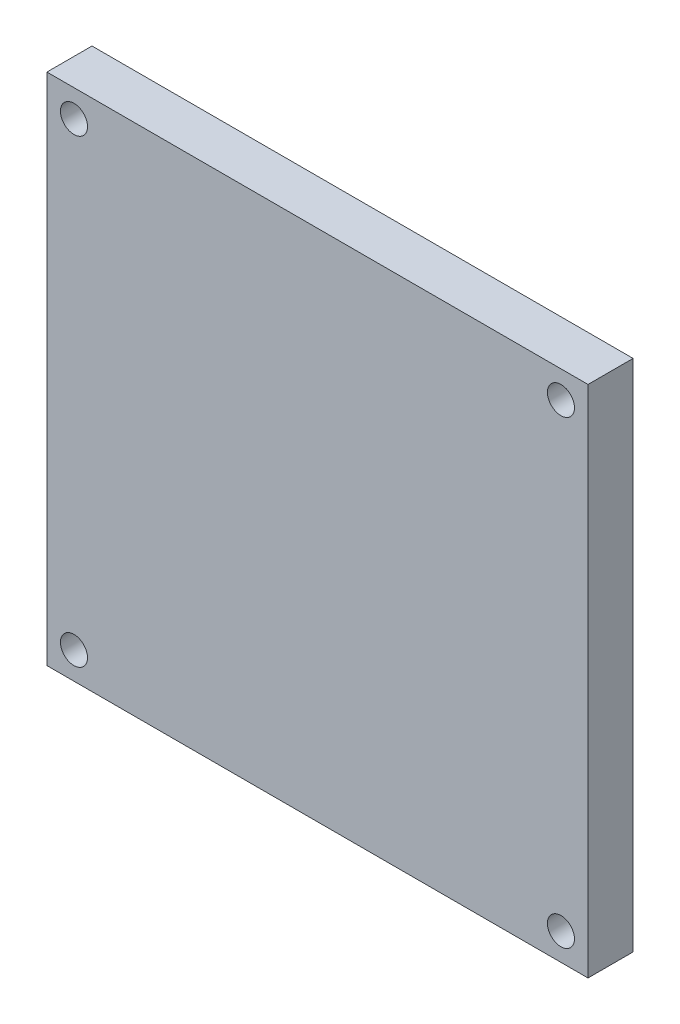
from build123d import *

# Parameters (mm, degrees)
SKETCH1_W           = 60
SKETCH1_H           = 57
BOSS_EXTRUDE1_DEPTH = 5
SKETCH2_W           = 2.280405405
SKETCH2_H           = 8
BOSS_EXTRUDE2_DEPTH = 1
SKETCH4_R           = 2.51
CUT_EXTRUDE1_DEPTH  = 1.5
SKETCH5_R           = 1.5
CUT_EXTRUDE2_DEPTH  = 5


with BuildPart() as part:
    # Sketch1 → Boss-Extrude1 (new body)
    with BuildSketch(Plane.XY):
        Rectangle(SKETCH1_W, SKETCH1_H)
    extrude(amount=BOSS_EXTRUDE1_DEPTH)

    # Sketch2 → Boss-Extrude2 (add)
    with BuildSketch(Plane(origin=(0, 0, 0), x_dir=(-1, 0, 0), z_dir=(0, 0, -1))):
        with BuildLine():
            Line((-24.20150669, -3.89957832), (-24.20150669, -1.614105347))
            Line((-24.20150669, -1.614105347), (-19.926168852, -1.614105347))
            add(Edge.make_bspline(
                [(-19.926168852, -1.614105347), (-19.887691328, -1.610282003), (-19.810774564, -1.602639119), (-19.717957698, -1.527413627), (-19.650822338, -1.426805485), (-19.644108729, -1.346040469), (-19.640695879, -1.304983726)],
                knots=[0, 0, 0, 0, 0.000113629, 0.000227144, 0.000344783, 0.000466416, 0.000466416, 0.000466416, 0.000466416], degree=3))
            add(Edge.make_bspline(
                [(-19.640695879, -1.304983726), (-19.644108729, -1.263926982), (-19.650822338, -1.183161967), (-19.717957698, -1.082553825), (-19.810774564, -1.007328333), (-19.887691328, -0.999685448), (-19.926168852, -0.995862104)],
                knots=[0, 0, 0, 0, 0.000121633, 0.000239272, 0.000352787, 0.000466416, 0.000466416, 0.000466416, 0.000466416], degree=3))
            Line((-19.926168852, -0.995862104), (-21.635628311, -0.995862104))
            add(Edge.make_bspline(
                [(-21.635628311, -0.995862104), (-21.722473931, -0.993687445), (-21.894088423, -0.989390129), (-22.145639266, -0.952415099), (-22.388446121, -0.895984066), (-22.620266099, -0.811525035), (-22.844531839, -0.707369457), (-23.057678623, -0.577615131), (-23.262284708, -0.426708764), (-23.452649356, -0.251991866), (-23.62635629, -0.060773048), (-23.782239865, 0.13987696), (-23.910026427, 0.352980665), (-24.018645568, 0.572977257), (-24.098985678, 0.804899998), (-24.158606031, 1.045612576), (-24.194868577, 1.296395056), (-24.199276132, 1.466857473), (-24.20150669, 1.553124382)],
                knots=[0, 0, 0, 0, 0.000260404, 0.00051458, 0.000761225, 0.001007001, 0.001253345, 0.001501902, 0.001754271, 0.002014932, 0.002275593, 0.002528645, 0.002775757, 0.003019779, 0.003263398, 0.003510441, 0.003762945, 0.004021662, 0.004021662, 0.004021662, 0.004021662], degree=3))
            add(Edge.make_bspline(
                [(-24.20150669, 1.553124382), (-24.199310434, 1.639395898), (-24.194984855, 1.809309767), (-24.158406918, 2.059479724), (-24.099003992, 2.299663062), (-24.018635935, 2.531577197), (-23.910046905, 2.751596069), (-23.782165923, 2.964617592), (-23.626896484, 3.165255727), (-23.452125797, 3.354980687), (-23.261800857, 3.529458704), (-23.058230483, 3.682361328), (-22.844462419, 3.811833778), (-22.620284578, 3.916109966), (-22.388441162, 4.000536837), (-22.145640635, 4.056976553), (-21.894088066, 4.093949215), (-21.722473811, 4.098246856), (-21.635628311, 4.10042168)],
                knots=[0, 0, 0, 0, 0.000258716, 0.000509548, 0.000756592, 0.00100021, 0.001244232, 0.001491345, 0.001744396, 0.002003812, 0.002264473, 0.002517852, 0.002766409, 0.003012753, 0.003258529, 0.003505174, 0.00375935, 0.004019754, 0.004019754, 0.004019754, 0.004019754], degree=3))
            Line((-21.635628311, 4.10042168), (-17.360290473, 4.10042168))
            Line((-17.360290473, 4.10042168), (-17.360290473, 1.814948707))
            Line((-17.360290473, 1.814948707), (-21.635628311, 1.814948707))
            add(Edge.make_bspline(
                [(-21.635628311, 1.814948707), (-21.673163777, 1.811723829), (-21.747515278, 1.805335884), (-21.841010332, 1.74431305), (-21.910115132, 1.658545586), (-21.917459333, 1.588071916), (-21.921101284, 1.553124382)],
                knots=[0, 0, 0, 0, 0.000111358, 0.000220583, 0.000325652, 0.000429011, 0.000429011, 0.000429011, 0.000429011], degree=3))
            add(Edge.make_bspline(
                [(-21.921101284, 1.553124382), (-21.91756183, 1.517580567), (-21.91048109, 1.446474549), (-21.841008801, 1.360242854), (-21.747515676, 1.299224645), (-21.67316391, 1.292836066), (-21.635628311, 1.289610869)],
                knots=[0, 0, 0, 0, 0.000105015, 0.000210085, 0.000319309, 0.000430668, 0.000430668, 0.000430668, 0.000430668], degree=3))
            Line((-21.635628311, 1.289610869), (-19.926168852, 1.289610869))
            add(Edge.make_bspline(
                [(-19.926168852, 1.289610869), (-19.839331642, 1.28739572), (-19.667733769, 1.283018394), (-19.415929918, 1.246607611), (-19.173255305, 1.187942153), (-18.941566461, 1.101725235), (-18.716965659, 0.996728305), (-18.505610415, 0.862111614), (-18.300840484, 0.708811097), (-18.111686128, 0.529707254), (-17.933776995, 0.338653809), (-17.782357465, 0.130767616), (-17.65124297, -0.083948062), (-17.54289339, -0.308551035), (-17.463094403, -0.544503606), (-17.403148798, -0.789048198), (-17.366860347, -1.0437628), (-17.362502597, -1.21702877), (-17.360290473, -1.304983726)],
                knots=[0, 0, 0, 0, 0.000260404, 0.00051458, 0.000761624, 0.001007974, 0.00125504, 0.001503925, 0.00175832, 0.00202127, 0.002284318, 0.002540407, 0.002791284, 0.003038351, 0.003286753, 0.003537079, 0.003792928, 0.004056707, 0.004056707, 0.004056707, 0.004056707], degree=3))
            add(Edge.make_bspline(
                [(-17.360290473, -1.304983726), (-17.362501109, -1.392939323), (-17.366855927, -1.566206558), (-17.403165707, -1.820911961), (-17.463032661, -2.065490475), (-17.543285409, -2.301800382), (-17.650857379, -2.527295701), (-17.78177601, -2.742334975), (-17.935027028, -2.948674433), (-18.110320474, -3.141618424), (-18.302180332, -3.318300264), (-18.504411397, -3.474347109), (-18.717604541, -3.606264295), (-18.941467932, -3.711841285), (-19.17328172, -3.797869765), (-19.415922644, -3.856586033), (-19.667735662, -3.892982991), (-19.839332278, -3.897362212), (-19.926168852, -3.89957832)],
                knots=[0, 0, 0, 0, 0.000263779, 0.000519628, 0.000769953, 0.001018356, 0.001266948, 0.001517825, 0.001772557, 0.002036855, 0.002298657, 0.002554077, 0.002802071, 0.003049138, 0.003295488, 0.003542531, 0.003796708, 0.004057112, 0.004057112, 0.004057112, 0.004057112], degree=3))
            Line((-19.926168852, -3.89957832), (-24.20150669, -3.89957832))
        make_face()
        Polygon((-14.461641825, -1.614105347), (-10.470087771, -1.614105347), (-10.470087771, -3.89957832), (-16.74204723, -3.89957832), (-16.74204723, 4.10042168), (-14.461641825, 4.10042168), align=None)
        with Locations((-8.791033717, 0.10042168)):
            Rectangle(SKETCH2_W, SKETCH2_H)
        with BuildLine():
            add(Edge.make_bspline(
                [(-3.6998175, 4.10042168), (-3.564523919, 4.096718379), (-3.297346775, 4.089405117), (-2.90412213, 4.035384866), (-2.527486782, 3.940755751), (-2.164236842, 3.814639035), (-1.817714669, 3.647969111), (-1.485822282, 3.445051878), (-1.169021856, 3.206348537), (-0.873064652, 2.932117609), (-0.60174879, 2.634325513), (-0.36091369, 2.319124581), (-0.159095712, 1.986578137), (0.005422052, 1.638163287), (0.134563515, 1.275574051), (0.226004455, 0.897482419), (0.280986911, 0.504072653), (0.28811807, 0.236296373), (0.291736554, 0.10042168)],
                knots=[0, 0, 0, 0, 0.000405831, 0.000801433, 0.00118777, 0.001569221, 0.001953038, 0.002338921, 0.00273453, 0.003140983, 0.003547541, 0.003941803, 0.004329129, 0.004712221, 0.005095827, 0.005481762, 0.005877364, 0.006284882, 0.006284882, 0.006284882, 0.006284882], degree=3))
            add(Edge.make_bspline(
                [(0.291736554, 0.10042168), (0.288118198, -0.035453107), (0.280987292, -0.303229572), (0.226003, -0.696637998), (0.134568816, -1.07473456), (0.005402388, -1.437305579), (-0.159022072, -1.785788514), (-0.361427925, -2.118461086), (-0.601230805, -2.434974519), (-0.872572249, -2.732962271), (-1.169592913, -3.005447414), (-1.485769847, -3.244233425), (-1.817669479, -3.44729741), (-2.164637643, -3.613170607), (-2.526841687, -3.742636676), (-2.90445399, -3.83381775), (-3.297295118, -3.888754843), (-3.564506554, -3.895939927), (-3.6998175, -3.89957832)],
                knots=[0, 0, 0, 0, 0.000407518, 0.000803121, 0.001189055, 0.001572661, 0.001955753, 0.002343079, 0.002738688, 0.003145246, 0.003550557, 0.003946166, 0.004332049, 0.004715867, 0.005097881, 0.005483816, 0.005879418, 0.006285249, 0.006285249, 0.006285249, 0.006285249], degree=3))
            Line((-3.6998175, -3.89957832), (-7.120425608, -3.89957832))
            Line((-7.120425608, -3.89957832), (-7.120425608, 4.10042168))
            Line((-7.120425608, 4.10042168), (-3.6998175, 4.10042168))
        make_face()
        with BuildLine():
            add(Edge.make_bspline(
                [(-3.6998175, -1.614105347), (-3.641742161, -1.612407855), (-3.527357761, -1.609064498), (-3.359302451, -1.58484257), (-3.197652085, -1.545603098), (-3.041793633, -1.492517478), (-2.89375923, -1.419811695), (-2.751566847, -1.333740853), (-2.615240861, -1.231869628), (-2.489054581, -1.11374345), (-2.37029547, -0.98740948), (-2.269642576, -0.849651853), (-2.18233483, -0.70707677), (-2.111139992, -0.558356324), (-2.056458738, -0.402536851), (-2.018247415, -0.240568132), (-1.993647819, -0.072055857), (-1.990345505, 0.042340347), (-1.988668852, 0.10042168)],
                knots=[0, 0, 0, 0, 0.000174191, 0.000343085, 0.000508194, 0.000672732, 0.00083592, 0.001001917, 0.001170836, 0.001345371, 0.001519906, 0.001690179, 0.001856176, 0.002020887, 0.00218383, 0.002350581, 0.002519475, 0.002693666, 0.002693666, 0.002693666, 0.002693666], degree=3))
            add(Edge.make_bspline(
                [(-1.988668852, 0.10042168), (-1.99034564, 0.158502912), (-1.993648221, 0.272898919), (-2.018245873, 0.441412633), (-2.056464392, 0.603376028), (-2.111119313, 0.759214977), (-2.182413263, 0.907862124), (-2.269109178, 1.050329693), (-2.370893, 1.18668432), (-2.488996449, 1.312921569), (-2.615181823, 1.431138332), (-2.752082926, 1.532610688), (-2.893231032, 1.620955694), (-3.041864193, 1.693245505), (-3.197633061, 1.746477551), (-3.359307656, 1.785677422), (-3.5273564, 1.809910083), (-3.641741702, 1.813251964), (-3.6998175, 1.814948707)],
                knots=[0, 0, 0, 0, 0.000174191, 0.000343085, 0.000509836, 0.00067278, 0.000837491, 0.001003487, 0.001172406, 0.001346941, 0.001521476, 0.001690395, 0.001857275, 0.002020463, 0.002185001, 0.00235011, 0.002519003, 0.002693195, 0.002693195, 0.002693195, 0.002693195], degree=3))
            Line((-3.6998175, 1.814948707), (-4.840020203, 1.814948707))
            Line((-4.840020203, 1.814948707), (-4.840020203, -1.614105347))
            Line((-4.840020203, -1.614105347), (-3.6998175, -1.614105347))
        make_face(mode=Mode.SUBTRACT)
        Polygon((7.720790608, 4.10042168), (7.720790608, 1.814948707), (3.159979797, 1.814948707), (3.159979797, 1.289610869), (6.580587905, 1.289610869), (6.580587905, -0.995862104), (3.159979797, -0.995862104), (3.159979797, -1.614105347), (7.720790608, -1.614105347), (7.720790608, -3.89957832), (0.879574392, -3.89957832), (0.879574392, 4.10042168), align=None)
        with BuildLine():
            add(Edge.make_bspline(
                [(12.614371689, 4.10042168), (12.701203222, 4.098191945), (12.872789877, 4.093785796), (13.124675554, 4.057585254), (13.366863352, 3.99819279), (13.599495414, 3.914934418), (13.822431293, 3.808441849), (14.036058165, 3.678680106), (14.238980193, 3.524377051), (14.429009396, 3.347523581), (14.606101497, 3.158024121), (14.758621546, 2.953247852), (14.88973352, 2.740039319), (14.996828872, 2.516603927), (15.077842388, 2.282804975), (15.137318345, 2.040332592), (15.173618679, 1.787891206), (15.178021843, 1.616306354), (15.180250067, 1.529475734)],
                knots=[0, 0, 0, 0, 0.000260404, 0.00051458, 0.000761624, 0.0010074, 0.001254466, 0.001501579, 0.001755975, 0.002017777, 0.00227958, 0.002532958, 0.002782392, 0.003029459, 0.003274671, 0.003523355, 0.003777532, 0.004037935, 0.004037935, 0.004037935, 0.004037935], degree=3))
            add(Edge.make_bspline(
                [(15.180250067, 1.529475734), (15.178093219, 1.442072782), (15.173858417, 1.270464001), (15.136884847, 1.017579551), (15.07815158, 0.7749493), (14.996831062, 0.540644412), (14.889928709, 0.318004757), (14.759621695, 0.104321748), (14.607030283, -0.100115102), (14.488427159, -0.225036388), (14.428560878, -0.288091834)],
                knots=[0, 0, 0, 0, 0.000262091, 0.000514595, 0.00076492, 0.001010132, 0.001257199, 0.001504312, 0.001760055, 0.002020716, 0.002020716, 0.002020716, 0.002020716], degree=3))
            add(Edge.make_bspline(
                [(14.428560878, -0.288091834), (14.373150955, -0.341475645), (14.264003889, -0.446631654), (14.086350826, -0.585233016), (13.903031588, -0.708329897), (13.773284131, -0.775209057), (13.708966283, -0.808362104)],
                knots=[0, 0, 0, 0, 0.000230678, 0.000454392, 0.000675056, 0.00089197, 0.00089197, 0.00089197, 0.00089197], degree=3))
            Line((13.708966283, -0.808362104), (16.793425743, -3.89957832))
            Line((16.793425743, -3.89957832), (13.567074392, -3.89957832))
            Line((13.567074392, -3.89957832), (10.619439256, -0.945186429))
            Line((10.619439256, -0.945186429), (10.619439256, -3.89957832))
            Line((10.619439256, -3.89957832), (8.339033851, -3.89957832))
            Line((8.339033851, -3.89957832), (8.339033851, 4.10042168))
            Line((8.339033851, 4.10042168), (12.614371689, 4.10042168))
        make_face()
        with BuildLine():
            Line((10.619439256, 1.814948707), (10.619439256, 1.244002761))
            Line((10.619439256, 1.244002761), (12.614371689, 1.244002761))
            add(Edge.make_bspline(
                [(12.614371689, 1.244002761), (12.652691795, 1.247420858), (12.728405378, 1.2541744), (12.821641364, 1.322961797), (12.888995239, 1.416333704), (12.896231628, 1.491797606), (12.899844662, 1.529475734)],
                knots=[0, 0, 0, 0, 0.000113314, 0.000223888, 0.00033586, 0.000447513, 0.000447513, 0.000447513, 0.000447513], degree=3))
            add(Edge.make_bspline(
                [(12.899844662, 1.529475734), (12.896439855, 1.567816179), (12.889712573, 1.643569951), (12.821018104, 1.736122149), (12.728465906, 1.804816618), (12.652712135, 1.8115439), (12.614371689, 1.814948707)],
                knots=[0, 0, 0, 0, 0.000113314, 0.000223888, 0.000334463, 0.000447777, 0.000447777, 0.000447777, 0.000447777], degree=3))
            Line((12.614371689, 1.814948707), (10.619439256, 1.814948707))
        make_face(mode=Mode.SUBTRACT)
        Polygon((19.790047365, -1.522889131), (17.411668986, -3.89957832), (14.185317635, -3.89957832), (18.1751825, 0.10042168), (15.79849331, 2.482178436), (15.79849331, 5.718664923), (19.790047365, 1.716975734), (22.166736554, 4.10042168), (25.393087905, 4.10042168), (21.40322304, 0.10042168), (23.779912229, -2.283024266), (23.779912229, -5.516132374), align=None)
    extrude(amount=BOSS_EXTRUDE2_DEPTH)

    # Sketch4 → Cut-Extrude1 (cut)
    with BuildSketch(Plane(origin=(0, 0, 0), x_dir=(-1, 0, 0), z_dir=(0, 0, -1))):
        with Locations((-27, 25.5)):
            Circle(SKETCH4_R)
        with Locations((27, 25.5)):
            Circle(SKETCH4_R)
        with Locations((27, -25.5)):
            Circle(SKETCH4_R)
        with Locations((-27, -25.5)):
            Circle(SKETCH4_R)
    extrude(amount=-CUT_EXTRUDE1_DEPTH, mode=Mode.SUBTRACT)

    # Sketch5 → Cut-Extrude2 (cut)
    with BuildSketch(Plane(origin=(0, 0, 0), x_dir=(-1, 0, 0), z_dir=(0, 0, -1))):
        with Locations((-27, 25.5)):
            Circle(SKETCH5_R)
        with Locations((27, 25.5)):
            Circle(SKETCH5_R)
        with Locations((27, -25.5)):
            Circle(SKETCH5_R)
        with Locations((-27, -25.5)):
            Circle(SKETCH5_R)
    extrude(amount=-CUT_EXTRUDE2_DEPTH, mode=Mode.SUBTRACT)


solid = part.part
